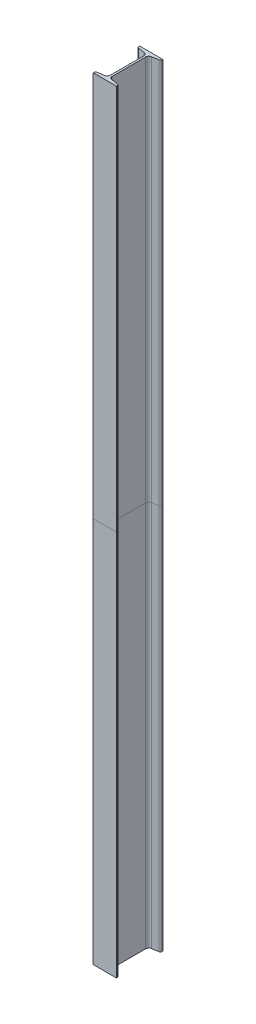
from build123d import *

# Parameters (mm, degrees)
SB_BEAM_120_X_12_1_DEPTH = 2000
SPLIT1_SURFACE_1_BACK    = 2005.495
SPLIT1_SURFACE_1_DEPTH   = 4010.99
SPLIT1_SURFACE_2_BACK    = 2005.495
SPLIT1_SURFACE_2_DEPTH   = 4010.99


with BuildPart() as part:
    # Sketch15 → Sb beam 120 X 12(1) (new body)
    with BuildSketch(Plane(origin=(0, 0, 0), x_dir=(-1, 0, 0), z_dir=(0, 1, 0))):
        with BuildLine():
            Line((-30, -60), (-30, -58.080070835))
            ThreePointArc((-30, -58.080070835), (-29.052095223, -55.494589303), (-26.657642624, -54.134502919))
            Line((-26.657642624, -54.134502919), (-9.184714752, -51.222135832))
            ThreePointArc((-9.184714752, -51.222135832), (-4.395809555, -48.501963064), (-2.5, -43.331))
            Line((-2.5, -43.331), (-2.5, 43.331))
            ThreePointArc((-2.5, 43.331), (-4.395809555, 48.501963064), (-9.184714752, 51.222135832))
            Line((-9.184714752, 51.222135832), (-26.657642624, 54.134502919))
            ThreePointArc((-26.657642624, 54.134502919), (-29.052095223, 55.494589303), (-30, 58.080070835))
            Line((-30, 58.080070835), (-30, 60))
            Line((-30, 60), (30, 60))
            Line((30, 60), (30, 58.080070835))
            ThreePointArc((30, 58.080070835), (29.052095223, 55.494589303), (26.657642624, 54.134502919))
            Line((26.657642624, 54.134502919), (9.184714752, 51.222135832))
            ThreePointArc((9.184714752, 51.222135832), (4.395809555, 48.501963064), (2.5, 43.331))
            Line((2.5, 43.331), (2.5, -43.331))
            ThreePointArc((2.5, -43.331), (4.395809555, -48.501963064), (9.184714752, -51.222135832))
            Line((9.184714752, -51.222135832), (26.657642624, -54.134502919))
            ThreePointArc((26.657642624, -54.134502919), (29.052095223, -55.494589303), (30, -58.080070835))
            Line((30, -58.080070835), (30, -60))
            Line((30, -60), (-30, -60))
        make_face()
    extrude(amount=SB_BEAM_120_X_12_1_DEPTH)


with BuildPart() as body_2:
    # Split1: the piece behind the surface
    add(part.part)
    # Split1 surface: a surface, the sketch's curves swept straight by 4010.99 mm
    with BuildLine(Plane(origin=(0, 0, -60), x_dir=(-1, 0, 0), z_dir=(0, 0, -1)).offset(-SPLIT1_SURFACE_1_BACK), mode=Mode.PRIVATE) as split1_surface_1_path:
        Line((-30, 1000), (30, 1000))
    split1_surface_1 = Shell.extrude(split1_surface_1_path.wire(), (0 * SPLIT1_SURFACE_1_DEPTH, 0 * SPLIT1_SURFACE_1_DEPTH, -1 * SPLIT1_SURFACE_1_DEPTH))
    split(bisect_by=split1_surface_1, keep=Keep.BOTTOM)


with BuildPart() as part_1:
    add(part.part)

    # Split1: split by a surface, the side it looks to stays
    # Split1 surface: a surface, the sketch's curves swept straight by 4010.99 mm
    with BuildLine(Plane(origin=(0, 0, -60), x_dir=(-1, 0, 0), z_dir=(0, 0, -1)).offset(-SPLIT1_SURFACE_2_BACK), mode=Mode.PRIVATE) as split1_surface_2_path:
        Line((-30, 1000), (30, 1000))
    split1_surface_2 = Shell.extrude(split1_surface_2_path.wire(), (0 * SPLIT1_SURFACE_2_DEPTH, 0 * SPLIT1_SURFACE_2_DEPTH, -1 * SPLIT1_SURFACE_2_DEPTH))
    split(bisect_by=split1_surface_2, keep=Keep.TOP)


solid = Compound([body_2.part, part_1.part])
